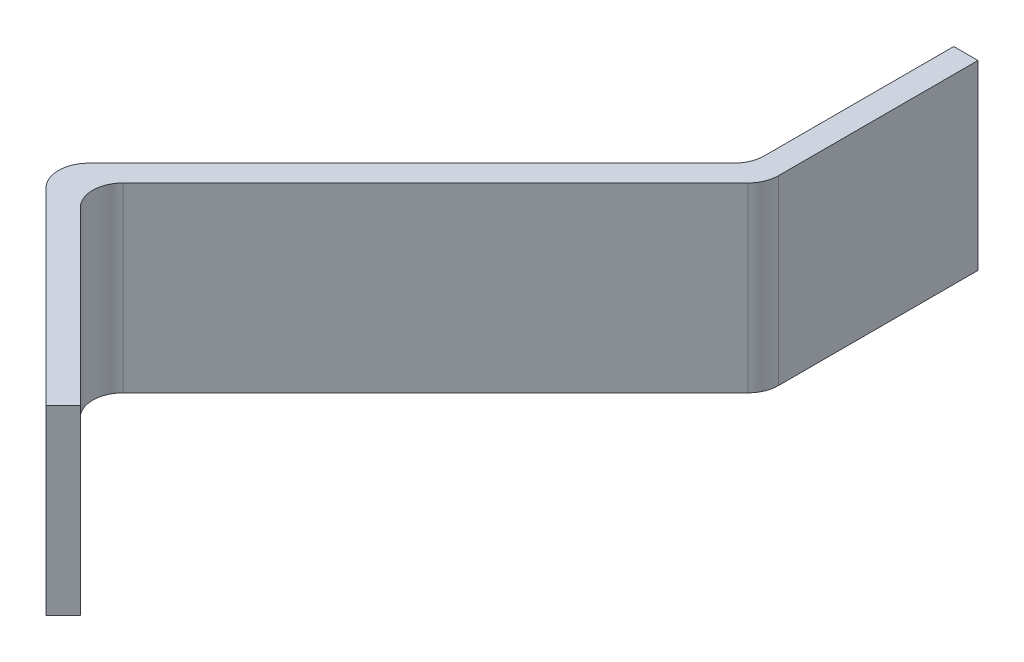
from build123d import *

# Parameters (mm, degrees)
BOSS_EXTRUDE1_DEPTH = 30


with BuildPart() as part:
    # Sketch1 → Boss-Extrude1 (new body)
    with BuildSketch(Plane(origin=(0, 7.5, 0), x_dir=(1, 0, 0), z_dir=(0, 1, 0))):
        with BuildLine():
            Line((-248.792121733, -1.76093065), (-217.679423361, -32.873629023))
            Line((-217.679423361, -32.873629023), (-214.850996236, -30.045201898))
            Line((-214.850996236, -30.045201898), (-243.135267484, -1.76093065))
            ThreePointArc((-243.135267484, -1.76093065), (-244.599733578, 1.774603256), (-243.135267484, 5.310137162))
            Line((-243.135267484, 5.310137162), (-191.566724989, 56.878679656))
            ThreePointArc((-191.566724989, 56.878679656), (-190.482861232, 58.500796401), (-190.102258895, 60.414213562))
            Line((-190.102258895, 60.414213562), (-190.102258895, 93.343145751))
            Line((-190.102258895, 93.343145751), (-194.102258895, 93.343145751))
            Line((-194.102258895, 93.343145751), (-194.102258895, 62.071067812))
            ThreePointArc((-194.102258895, 62.071067812), (-194.482861232, 60.15765065), (-195.566724989, 58.535533906))
            Line((-195.566724989, 58.535533906), (-248.792121733, 5.310137162))
            ThreePointArc((-248.792121733, 5.310137162), (-250.256587827, 1.774603256), (-248.792121733, -1.76093065))
        make_face()
    extrude(amount=-BOSS_EXTRUDE1_DEPTH)


solid = part.part
